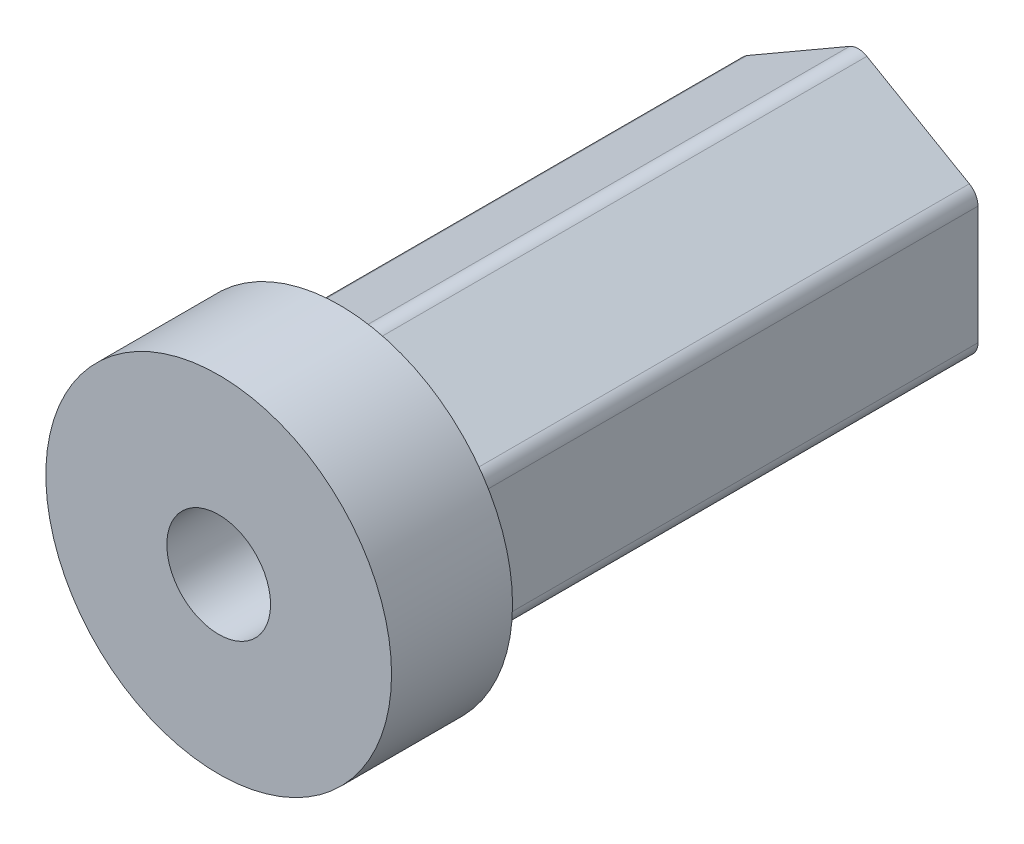
from build123d import *

# Parameters (mm, degrees)
CUT_EXTRUDE1_DEPTH = 30
FILLET1_R          = 1


with BuildPart() as part:
    # Sketch2 → Revolve1 (revolve)
    with BuildSketch(Plane(origin=(0, 0, 0), x_dir=(0, 0, -1), z_dir=(1, 0, 0))):
        Polygon((-12, 3), (25, 3), (25, 8), (-5, 8), (-5, 10), (-12, 10), align=None)
    revolve(axis=Axis((0, 0, 0), (0, 0, -1)))

    # Sketch3 → Cut-Extrude1 (cut)
    with BuildSketch(Plane(origin=(0, 0, -25), x_dir=(-1, 0, 0), z_dir=(0, 0, -1))):
        with BuildLine():
            ThreePointArc((0, 8), (-4, 6.92820323), (-6.92820323, 4))
            Line((-6.92820323, 4), (0, 8))
        make_face()
        with BuildLine():
            ThreePointArc((-6.92820323, 4), (-8, 0), (-6.92820323, -4))
            Line((-6.92820323, -4), (-6.92820323, 4))
        make_face()
        with BuildLine():
            ThreePointArc((-6.92820323, -4), (-4, -6.92820323), (0, -8))
            Line((0, -8), (-6.92820323, -4))
        make_face()
        with BuildLine():
            Line((6.92820323, -4), (0, -8))
            ThreePointArc((0, -8), (4, -6.92820323), (6.92820323, -4))
        make_face()
        with BuildLine():
            Line((6.92820323, 4), (6.92820323, -4))
            ThreePointArc((6.92820323, -4), (7.72740661, -2.070552361), (8, 0))
            ThreePointArc((8, 0), (7.72740661, 2.070552361), (6.92820323, 4))
        make_face()
        with BuildLine():
            Line((0, 8), (6.92820323, 4))
            ThreePointArc((6.92820323, 4), (4, 6.92820323), (0, 8))
        make_face()
    extrude(amount=-CUT_EXTRUDE1_DEPTH, mode=Mode.SUBTRACT)

    # Fillet1
    fillet1_edges = [part.edges().sort_by_distance(p)[0] for p in [
        (0, 8, -10),
        (6.92820323, 4, -10),
        (6.92820323, -4, -10),
        (0, -8, -10),
        (-6.92820323, -4, -10),
        (-6.92820323, 4, -10),
    ]]
    fillet(fillet1_edges, radius=FILLET1_R)


solid = part.part
